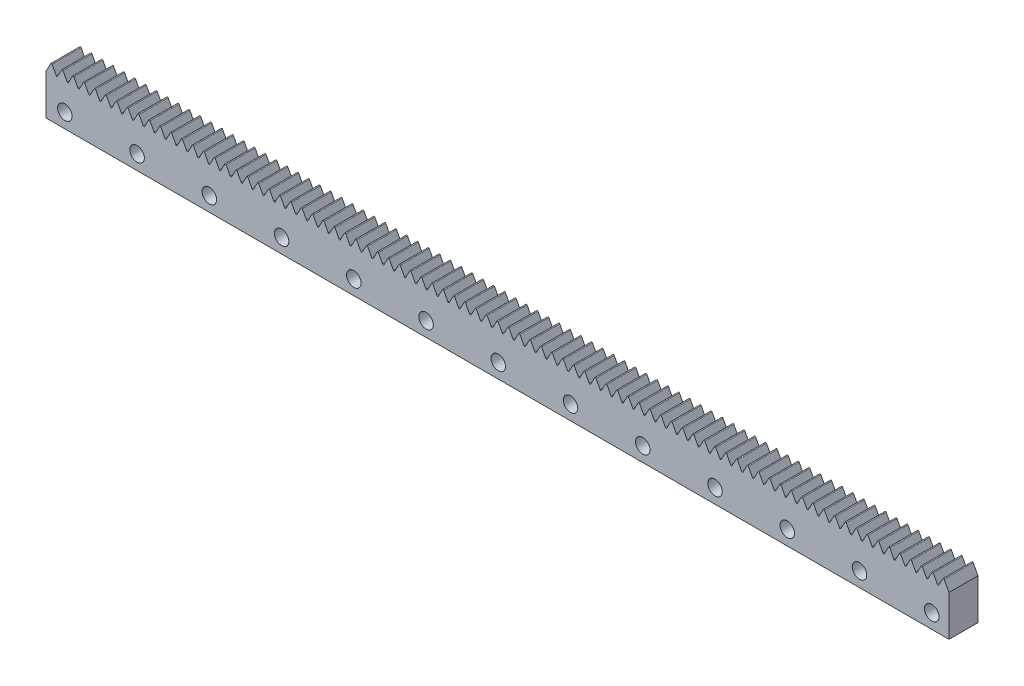
from build123d import *

# Parameters (mm, degrees)
BOSS_EXTRUDE1_DEPTH = 4
SKETCH2_R           = 1
CUT_EXTRUDE1_DEPTH  = 5


with BuildPart() as part:
    # Sketch1 → Boss-Extrude1 (new body)
    with BuildSketch(Plane.XY):
        with BuildLine():
            Line((0, 0), (124.5, 0))
            Line((124.5, 0), (124.5, 5.6))
            Line((124.5, 5.6), (123.838147997, 6.835457072))
            ThreePointArc((123.838147997, 6.835457072), (123.75, 6.888234931), (123.661852003, 6.835457072))
            Line((123.661852003, 6.835457072), (123.088147997, 5.764542928))
            ThreePointArc((123.088147997, 5.764542928), (123, 5.711765069), (122.911852003, 5.764542928))
            Line((122.911852003, 5.764542928), (122.338147997, 6.835457072))
            ThreePointArc((122.338147997, 6.835457072), (122.25, 6.888234931), (122.161852003, 6.835457072))
            Line((122.161852003, 6.835457072), (121.588147997, 5.764542928))
            ThreePointArc((121.588147997, 5.764542928), (121.5, 5.711765069), (121.411852003, 5.764542928))
            Line((121.411852003, 5.764542928), (120.838147997, 6.835457072))
            ThreePointArc((120.838147997, 6.835457072), (120.75, 6.888234931), (120.661852003, 6.835457072))
            Line((120.661852003, 6.835457072), (120.088147997, 5.764542928))
            ThreePointArc((120.088147997, 5.764542928), (120, 5.711765069), (119.911852003, 5.764542928))
            Line((119.911852003, 5.764542928), (119.338147997, 6.835457072))
            ThreePointArc((119.338147997, 6.835457072), (119.25, 6.888234931), (119.161852003, 6.835457072))
            Line((119.161852003, 6.835457072), (118.588147997, 5.764542928))
            ThreePointArc((118.588147997, 5.764542928), (118.5, 5.711765069), (118.411852003, 5.764542928))
            Line((118.411852003, 5.764542928), (117.838147997, 6.835457072))
            ThreePointArc((117.838147997, 6.835457072), (117.75, 6.888234931), (117.661852003, 6.835457072))
            Line((117.661852003, 6.835457072), (117.088147997, 5.764542928))
            ThreePointArc((117.088147997, 5.764542928), (117, 5.711765069), (116.911852003, 5.764542928))
            Line((116.911852003, 5.764542928), (116.338147997, 6.835457072))
            ThreePointArc((116.338147997, 6.835457072), (116.25, 6.888234931), (116.161852003, 6.835457072))
            Line((116.161852003, 6.835457072), (115.588147997, 5.764542928))
            ThreePointArc((115.588147997, 5.764542928), (115.5, 5.711765069), (115.411852003, 5.764542928))
            Line((115.411852003, 5.764542928), (114.838147997, 6.835457072))
            ThreePointArc((114.838147997, 6.835457072), (114.75, 6.888234931), (114.661852003, 6.835457072))
            Line((114.661852003, 6.835457072), (114.088147997, 5.764542928))
            ThreePointArc((114.088147997, 5.764542928), (114, 5.711765069), (113.911852003, 5.764542928))
            Line((113.911852003, 5.764542928), (113.338147997, 6.835457072))
            ThreePointArc((113.338147997, 6.835457072), (113.25, 6.888234931), (113.161852003, 6.835457072))
            Line((113.161852003, 6.835457072), (112.588147997, 5.764542928))
            ThreePointArc((112.588147997, 5.764542928), (112.5, 5.711765069), (112.411852003, 5.764542928))
            Line((112.411852003, 5.764542928), (111.838147997, 6.835457072))
            ThreePointArc((111.838147997, 6.835457072), (111.75, 6.888234931), (111.661852003, 6.835457072))
            Line((111.661852003, 6.835457072), (111.088147997, 5.764542928))
            ThreePointArc((111.088147997, 5.764542928), (111, 5.711765069), (110.911852003, 5.764542928))
            Line((110.911852003, 5.764542928), (110.338147997, 6.835457072))
            ThreePointArc((110.338147997, 6.835457072), (110.25, 6.888234931), (110.161852003, 6.835457072))
            Line((110.161852003, 6.835457072), (109.588147997, 5.764542928))
            ThreePointArc((109.588147997, 5.764542928), (109.5, 5.711765069), (109.411852003, 5.764542928))
            Line((109.411852003, 5.764542928), (108.838147997, 6.835457072))
            ThreePointArc((108.838147997, 6.835457072), (108.75, 6.888234931), (108.661852003, 6.835457072))
            Line((108.661852003, 6.835457072), (108.088147997, 5.764542928))
            ThreePointArc((108.088147997, 5.764542928), (108, 5.711765069), (107.911852003, 5.764542928))
            Line((107.911852003, 5.764542928), (107.338147997, 6.835457072))
            ThreePointArc((107.338147997, 6.835457072), (107.25, 6.888234931), (107.161852003, 6.835457072))
            Line((107.161852003, 6.835457072), (106.588147997, 5.764542928))
            ThreePointArc((106.588147997, 5.764542928), (106.5, 5.711765069), (106.411852003, 5.764542928))
            Line((106.411852003, 5.764542928), (105.838147997, 6.835457072))
            ThreePointArc((105.838147997, 6.835457072), (105.75, 6.888234931), (105.661852003, 6.835457072))
            Line((105.661852003, 6.835457072), (105.088147997, 5.764542928))
            ThreePointArc((105.088147997, 5.764542928), (105, 5.711765069), (104.911852003, 5.764542928))
            Line((104.911852003, 5.764542928), (104.338147997, 6.835457072))
            ThreePointArc((104.338147997, 6.835457072), (104.25, 6.888234931), (104.161852003, 6.835457072))
            Line((104.161852003, 6.835457072), (103.588147997, 5.764542928))
            ThreePointArc((103.588147997, 5.764542928), (103.5, 5.711765069), (103.411852003, 5.764542928))
            Line((103.411852003, 5.764542928), (102.838147997, 6.835457072))
            ThreePointArc((102.838147997, 6.835457072), (102.75, 6.888234931), (102.661852003, 6.835457072))
            Line((102.661852003, 6.835457072), (102.088147997, 5.764542928))
            ThreePointArc((102.088147997, 5.764542928), (102, 5.711765069), (101.911852003, 5.764542928))
            Line((101.911852003, 5.764542928), (101.338147997, 6.835457072))
            ThreePointArc((101.338147997, 6.835457072), (101.25, 6.888234931), (101.161852003, 6.835457072))
            Line((101.161852003, 6.835457072), (100.588147997, 5.764542928))
            ThreePointArc((100.588147997, 5.764542928), (100.5, 5.711765069), (100.411852003, 5.764542928))
            Line((100.411852003, 5.764542928), (99.838147997, 6.835457072))
            ThreePointArc((99.838147997, 6.835457072), (99.75, 6.888234931), (99.661852003, 6.835457072))
            Line((99.661852003, 6.835457072), (99.088147997, 5.764542928))
            ThreePointArc((99.088147997, 5.764542928), (99, 5.711765069), (98.911852003, 5.764542928))
            Line((98.911852003, 5.764542928), (98.338147997, 6.835457072))
            ThreePointArc((98.338147997, 6.835457072), (98.25, 6.888234931), (98.161852003, 6.835457072))
            Line((98.161852003, 6.835457072), (97.588147997, 5.764542928))
            ThreePointArc((97.588147997, 5.764542928), (97.5, 5.711765069), (97.411852003, 5.764542928))
            Line((97.411852003, 5.764542928), (96.838147997, 6.835457072))
            ThreePointArc((96.838147997, 6.835457072), (96.75, 6.888234931), (96.661852003, 6.835457072))
            Line((96.661852003, 6.835457072), (96.088147997, 5.764542928))
            ThreePointArc((96.088147997, 5.764542928), (96, 5.711765069), (95.911852003, 5.764542928))
            Line((95.911852003, 5.764542928), (95.338147997, 6.835457072))
            ThreePointArc((95.338147997, 6.835457072), (95.25, 6.888234931), (95.161852003, 6.835457072))
            Line((95.161852003, 6.835457072), (94.588147997, 5.764542928))
            ThreePointArc((94.588147997, 5.764542928), (94.5, 5.711765069), (94.411852003, 5.764542928))
            Line((94.411852003, 5.764542928), (93.838147997, 6.835457072))
            ThreePointArc((93.838147997, 6.835457072), (93.75, 6.888234931), (93.661852003, 6.835457072))
            Line((93.661852003, 6.835457072), (93.088147997, 5.764542928))
            ThreePointArc((93.088147997, 5.764542928), (93, 5.711765069), (92.911852003, 5.764542928))
            Line((92.911852003, 5.764542928), (92.338147997, 6.835457072))
            ThreePointArc((92.338147997, 6.835457072), (92.25, 6.888234931), (92.161852003, 6.835457072))
            Line((92.161852003, 6.835457072), (91.588147997, 5.764542928))
            ThreePointArc((91.588147997, 5.764542928), (91.5, 5.711765069), (91.411852003, 5.764542928))
            Line((91.411852003, 5.764542928), (90.838147997, 6.835457072))
            ThreePointArc((90.838147997, 6.835457072), (90.75, 6.888234931), (90.661852003, 6.835457072))
            Line((90.661852003, 6.835457072), (90.088147997, 5.764542928))
            ThreePointArc((90.088147997, 5.764542928), (90, 5.711765069), (89.911852003, 5.764542928))
            Line((89.911852003, 5.764542928), (89.338147997, 6.835457072))
            ThreePointArc((89.338147997, 6.835457072), (89.25, 6.888234931), (89.161852003, 6.835457072))
            Line((89.161852003, 6.835457072), (88.588147997, 5.764542928))
            ThreePointArc((88.588147997, 5.764542928), (88.5, 5.711765069), (88.411852003, 5.764542928))
            Line((88.411852003, 5.764542928), (87.838147997, 6.835457072))
            ThreePointArc((87.838147997, 6.835457072), (87.75, 6.888234931), (87.661852003, 6.835457072))
            Line((87.661852003, 6.835457072), (87.088147997, 5.764542928))
            ThreePointArc((87.088147997, 5.764542928), (87, 5.711765069), (86.911852003, 5.764542928))
            Line((86.911852003, 5.764542928), (86.338147997, 6.835457072))
            ThreePointArc((86.338147997, 6.835457072), (86.25, 6.888234931), (86.161852003, 6.835457072))
            Line((86.161852003, 6.835457072), (85.588147997, 5.764542928))
            ThreePointArc((85.588147997, 5.764542928), (85.5, 5.711765069), (85.411852003, 5.764542928))
            Line((85.411852003, 5.764542928), (84.838147997, 6.835457072))
            ThreePointArc((84.838147997, 6.835457072), (84.75, 6.888234931), (84.661852003, 6.835457072))
            Line((84.661852003, 6.835457072), (84.088147997, 5.764542928))
            ThreePointArc((84.088147997, 5.764542928), (84, 5.711765069), (83.911852003, 5.764542928))
            Line((83.911852003, 5.764542928), (83.338147997, 6.835457072))
            ThreePointArc((83.338147997, 6.835457072), (83.25, 6.888234931), (83.161852003, 6.835457072))
            Line((83.161852003, 6.835457072), (82.588147997, 5.764542928))
            ThreePointArc((82.588147997, 5.764542928), (82.5, 5.711765069), (82.411852003, 5.764542928))
            Line((82.411852003, 5.764542928), (81.838147997, 6.835457072))
            ThreePointArc((81.838147997, 6.835457072), (81.75, 6.888234931), (81.661852003, 6.835457072))
            Line((81.661852003, 6.835457072), (81.088147997, 5.764542928))
            ThreePointArc((81.088147997, 5.764542928), (81, 5.711765069), (80.911852003, 5.764542928))
            Line((80.911852003, 5.764542928), (80.338147997, 6.835457072))
            ThreePointArc((80.338147997, 6.835457072), (80.25, 6.888234931), (80.161852003, 6.835457072))
            Line((80.161852003, 6.835457072), (79.588147997, 5.764542928))
            ThreePointArc((79.588147997, 5.764542928), (79.5, 5.711765069), (79.411852003, 5.764542928))
            Line((79.411852003, 5.764542928), (78.838147997, 6.835457072))
            ThreePointArc((78.838147997, 6.835457072), (78.75, 6.888234931), (78.661852003, 6.835457072))
            Line((78.661852003, 6.835457072), (78.088147997, 5.764542928))
            ThreePointArc((78.088147997, 5.764542928), (78, 5.711765069), (77.911852003, 5.764542928))
            Line((77.911852003, 5.764542928), (77.338147997, 6.835457072))
            ThreePointArc((77.338147997, 6.835457072), (77.25, 6.888234931), (77.161852003, 6.835457072))
            Line((77.161852003, 6.835457072), (76.588147997, 5.764542928))
            ThreePointArc((76.588147997, 5.764542928), (76.5, 5.711765069), (76.411852003, 5.764542928))
            Line((76.411852003, 5.764542928), (75.838147997, 6.835457072))
            ThreePointArc((75.838147997, 6.835457072), (75.75, 6.888234931), (75.661852003, 6.835457072))
            Line((75.661852003, 6.835457072), (75.088147997, 5.764542928))
            ThreePointArc((75.088147997, 5.764542928), (75, 5.711765069), (74.911852003, 5.764542928))
            Line((74.911852003, 5.764542928), (74.338147997, 6.835457072))
            ThreePointArc((74.338147997, 6.835457072), (74.25, 6.888234931), (74.161852003, 6.835457072))
            Line((74.161852003, 6.835457072), (73.588147997, 5.764542928))
            ThreePointArc((73.588147997, 5.764542928), (73.5, 5.711765069), (73.411852003, 5.764542928))
            Line((73.411852003, 5.764542928), (72.838147997, 6.835457072))
            ThreePointArc((72.838147997, 6.835457072), (72.75, 6.888234931), (72.661852003, 6.835457072))
            Line((72.661852003, 6.835457072), (72.088147997, 5.764542928))
            ThreePointArc((72.088147997, 5.764542928), (72, 5.711765069), (71.911852003, 5.764542928))
            Line((71.911852003, 5.764542928), (71.338147997, 6.835457072))
            ThreePointArc((71.338147997, 6.835457072), (71.25, 6.888234931), (71.161852003, 6.835457072))
            Line((71.161852003, 6.835457072), (70.588147997, 5.764542928))
            ThreePointArc((70.588147997, 5.764542928), (70.5, 5.711765069), (70.411852003, 5.764542928))
            Line((70.411852003, 5.764542928), (69.838147997, 6.835457072))
            ThreePointArc((69.838147997, 6.835457072), (69.75, 6.888234931), (69.661852003, 6.835457072))
            Line((69.661852003, 6.835457072), (69.088147997, 5.764542928))
            ThreePointArc((69.088147997, 5.764542928), (69, 5.711765069), (68.911852003, 5.764542928))
            Line((68.911852003, 5.764542928), (68.338147997, 6.835457072))
            ThreePointArc((68.338147997, 6.835457072), (68.25, 6.888234931), (68.161852003, 6.835457072))
            Line((68.161852003, 6.835457072), (67.588147997, 5.764542928))
            ThreePointArc((67.588147997, 5.764542928), (67.5, 5.711765069), (67.411852003, 5.764542928))
            Line((67.411852003, 5.764542928), (66.838147997, 6.835457072))
            ThreePointArc((66.838147997, 6.835457072), (66.75, 6.888234931), (66.661852003, 6.835457072))
            Line((66.661852003, 6.835457072), (66.088147997, 5.764542928))
            ThreePointArc((66.088147997, 5.764542928), (66, 5.711765069), (65.911852003, 5.764542928))
            Line((65.911852003, 5.764542928), (65.338147997, 6.835457072))
            ThreePointArc((65.338147997, 6.835457072), (65.25, 6.888234931), (65.161852003, 6.835457072))
            Line((65.161852003, 6.835457072), (64.588147997, 5.764542928))
            ThreePointArc((64.588147997, 5.764542928), (64.5, 5.711765069), (64.411852003, 5.764542928))
            Line((64.411852003, 5.764542928), (63.838147997, 6.835457072))
            ThreePointArc((63.838147997, 6.835457072), (63.75, 6.888234931), (63.661852003, 6.835457072))
            Line((63.661852003, 6.835457072), (63.088147997, 5.764542928))
            ThreePointArc((63.088147997, 5.764542928), (63, 5.711765069), (62.911852003, 5.764542928))
            Line((62.911852003, 5.764542928), (62.338147997, 6.835457072))
            ThreePointArc((62.338147997, 6.835457072), (62.25, 6.888234931), (62.161852003, 6.835457072))
            Line((62.161852003, 6.835457072), (61.588147997, 5.764542928))
            ThreePointArc((61.588147997, 5.764542928), (61.5, 5.711765069), (61.411852003, 5.764542928))
            Line((61.411852003, 5.764542928), (60.838147997, 6.835457072))
            ThreePointArc((60.838147997, 6.835457072), (60.75, 6.888234931), (60.661852003, 6.835457072))
            Line((60.661852003, 6.835457072), (60.088147997, 5.764542928))
            ThreePointArc((60.088147997, 5.764542928), (60, 5.711765069), (59.911852003, 5.764542928))
            Line((59.911852003, 5.764542928), (59.338147997, 6.835457072))
            ThreePointArc((59.338147997, 6.835457072), (59.25, 6.888234931), (59.161852003, 6.835457072))
            Line((59.161852003, 6.835457072), (58.588147997, 5.764542928))
            ThreePointArc((58.588147997, 5.764542928), (58.5, 5.711765069), (58.411852003, 5.764542928))
            Line((58.411852003, 5.764542928), (57.838147997, 6.835457072))
            ThreePointArc((57.838147997, 6.835457072), (57.75, 6.888234931), (57.661852003, 6.835457072))
            Line((57.661852003, 6.835457072), (57.088147997, 5.764542928))
            ThreePointArc((57.088147997, 5.764542928), (57, 5.711765069), (56.911852003, 5.764542928))
            Line((56.911852003, 5.764542928), (56.338147997, 6.835457072))
            ThreePointArc((56.338147997, 6.835457072), (56.25, 6.888234931), (56.161852003, 6.835457072))
            Line((56.161852003, 6.835457072), (55.588147997, 5.764542928))
            ThreePointArc((55.588147997, 5.764542928), (55.5, 5.711765069), (55.411852003, 5.764542928))
            Line((55.411852003, 5.764542928), (54.838147997, 6.835457072))
            ThreePointArc((54.838147997, 6.835457072), (54.75, 6.888234931), (54.661852003, 6.835457072))
            Line((54.661852003, 6.835457072), (54.088147997, 5.764542928))
            ThreePointArc((54.088147997, 5.764542928), (54, 5.711765069), (53.911852003, 5.764542928))
            Line((53.911852003, 5.764542928), (53.338147997, 6.835457072))
            ThreePointArc((53.338147997, 6.835457072), (53.25, 6.888234931), (53.161852003, 6.835457072))
            Line((53.161852003, 6.835457072), (52.588147997, 5.764542928))
            ThreePointArc((52.588147997, 5.764542928), (52.5, 5.711765069), (52.411852003, 5.764542928))
            Line((52.411852003, 5.764542928), (51.838147997, 6.835457072))
            ThreePointArc((51.838147997, 6.835457072), (51.75, 6.888234931), (51.661852003, 6.835457072))
            Line((51.661852003, 6.835457072), (51.088147997, 5.764542928))
            ThreePointArc((51.088147997, 5.764542928), (51, 5.711765069), (50.911852003, 5.764542928))
            Line((50.911852003, 5.764542928), (50.338147997, 6.835457072))
            ThreePointArc((50.338147997, 6.835457072), (50.25, 6.888234931), (50.161852003, 6.835457072))
            Line((50.161852003, 6.835457072), (49.588147997, 5.764542928))
            ThreePointArc((49.588147997, 5.764542928), (49.5, 5.711765069), (49.411852003, 5.764542928))
            Line((49.411852003, 5.764542928), (48.838147997, 6.835457072))
            ThreePointArc((48.838147997, 6.835457072), (48.75, 6.888234931), (48.661852003, 6.835457072))
            Line((48.661852003, 6.835457072), (48.088147997, 5.764542928))
            ThreePointArc((48.088147997, 5.764542928), (48, 5.711765069), (47.911852003, 5.764542928))
            Line((47.911852003, 5.764542928), (47.338147997, 6.835457072))
            ThreePointArc((47.338147997, 6.835457072), (47.25, 6.888234931), (47.161852003, 6.835457072))
            Line((47.161852003, 6.835457072), (46.588147997, 5.764542928))
            ThreePointArc((46.588147997, 5.764542928), (46.5, 5.711765069), (46.411852003, 5.764542928))
            Line((46.411852003, 5.764542928), (45.838147997, 6.835457072))
            ThreePointArc((45.838147997, 6.835457072), (45.75, 6.888234931), (45.661852003, 6.835457072))
            Line((45.661852003, 6.835457072), (45.088147997, 5.764542928))
            ThreePointArc((45.088147997, 5.764542928), (45, 5.711765069), (44.911852003, 5.764542928))
            Line((44.911852003, 5.764542928), (44.338147997, 6.835457072))
            ThreePointArc((44.338147997, 6.835457072), (44.25, 6.888234931), (44.161852003, 6.835457072))
            Line((44.161852003, 6.835457072), (43.588147997, 5.764542928))
            ThreePointArc((43.588147997, 5.764542928), (43.5, 5.711765069), (43.411852003, 5.764542928))
            Line((43.411852003, 5.764542928), (42.838147997, 6.835457072))
            ThreePointArc((42.838147997, 6.835457072), (42.75, 6.888234931), (42.661852003, 6.835457072))
            Line((42.661852003, 6.835457072), (42.088147997, 5.764542928))
            ThreePointArc((42.088147997, 5.764542928), (42, 5.711765069), (41.911852003, 5.764542928))
            Line((41.911852003, 5.764542928), (41.338147997, 6.835457072))
            ThreePointArc((41.338147997, 6.835457072), (41.25, 6.888234931), (41.161852003, 6.835457072))
            Line((41.161852003, 6.835457072), (40.588147997, 5.764542928))
            ThreePointArc((40.588147997, 5.764542928), (40.5, 5.711765069), (40.411852003, 5.764542928))
            Line((40.411852003, 5.764542928), (39.838147997, 6.835457072))
            ThreePointArc((39.838147997, 6.835457072), (39.75, 6.888234931), (39.661852003, 6.835457072))
            Line((39.661852003, 6.835457072), (39.088147997, 5.764542928))
            ThreePointArc((39.088147997, 5.764542928), (39, 5.711765069), (38.911852003, 5.764542928))
            Line((38.911852003, 5.764542928), (38.338147997, 6.835457072))
            ThreePointArc((38.338147997, 6.835457072), (38.25, 6.888234931), (38.161852003, 6.835457072))
            Line((38.161852003, 6.835457072), (37.588147997, 5.764542928))
            ThreePointArc((37.588147997, 5.764542928), (37.5, 5.711765069), (37.411852003, 5.764542928))
            Line((37.411852003, 5.764542928), (36.838147997, 6.835457072))
            ThreePointArc((36.838147997, 6.835457072), (36.75, 6.888234931), (36.661852003, 6.835457072))
            Line((36.661852003, 6.835457072), (36.088147997, 5.764542928))
            ThreePointArc((36.088147997, 5.764542928), (36, 5.711765069), (35.911852003, 5.764542928))
            Line((35.911852003, 5.764542928), (35.338147997, 6.835457072))
            ThreePointArc((35.338147997, 6.835457072), (35.25, 6.888234931), (35.161852003, 6.835457072))
            Line((35.161852003, 6.835457072), (34.588147997, 5.764542928))
            ThreePointArc((34.588147997, 5.764542928), (34.5, 5.711765069), (34.411852003, 5.764542928))
            Line((34.411852003, 5.764542928), (33.838147997, 6.835457072))
            ThreePointArc((33.838147997, 6.835457072), (33.75, 6.888234931), (33.661852003, 6.835457072))
            Line((33.661852003, 6.835457072), (33.088147997, 5.764542928))
            ThreePointArc((33.088147997, 5.764542928), (33, 5.711765069), (32.911852003, 5.764542928))
            Line((32.911852003, 5.764542928), (32.338147997, 6.835457072))
            ThreePointArc((32.338147997, 6.835457072), (32.25, 6.888234931), (32.161852003, 6.835457072))
            Line((32.161852003, 6.835457072), (31.588147997, 5.764542928))
            ThreePointArc((31.588147997, 5.764542928), (31.5, 5.711765069), (31.411852003, 5.764542928))
            Line((31.411852003, 5.764542928), (30.838147997, 6.835457072))
            ThreePointArc((30.838147997, 6.835457072), (30.75, 6.888234931), (30.661852003, 6.835457072))
            Line((30.661852003, 6.835457072), (30.088147997, 5.764542928))
            ThreePointArc((30.088147997, 5.764542928), (30, 5.711765069), (29.911852003, 5.764542928))
            Line((29.911852003, 5.764542928), (29.338147997, 6.835457072))
            ThreePointArc((29.338147997, 6.835457072), (29.25, 6.888234931), (29.161852003, 6.835457072))
            Line((29.161852003, 6.835457072), (28.588147997, 5.764542928))
            ThreePointArc((28.588147997, 5.764542928), (28.5, 5.711765069), (28.411852003, 5.764542928))
            Line((28.411852003, 5.764542928), (27.838147997, 6.835457072))
            ThreePointArc((27.838147997, 6.835457072), (27.75, 6.888234931), (27.661852003, 6.835457072))
            Line((27.661852003, 6.835457072), (27.088147997, 5.764542928))
            ThreePointArc((27.088147997, 5.764542928), (27, 5.711765069), (26.911852003, 5.764542928))
            Line((26.911852003, 5.764542928), (26.338147997, 6.835457072))
            ThreePointArc((26.338147997, 6.835457072), (26.25, 6.888234931), (26.161852003, 6.835457072))
            Line((26.161852003, 6.835457072), (25.588147997, 5.764542928))
            ThreePointArc((25.588147997, 5.764542928), (25.5, 5.711765069), (25.411852003, 5.764542928))
            Line((25.411852003, 5.764542928), (24.838147997, 6.835457072))
            ThreePointArc((24.838147997, 6.835457072), (24.75, 6.888234931), (24.661852003, 6.835457072))
            Line((24.661852003, 6.835457072), (24.088147997, 5.764542928))
            ThreePointArc((24.088147997, 5.764542928), (24, 5.711765069), (23.911852003, 5.764542928))
            Line((23.911852003, 5.764542928), (23.338147997, 6.835457072))
            ThreePointArc((23.338147997, 6.835457072), (23.25, 6.888234931), (23.161852003, 6.835457072))
            Line((23.161852003, 6.835457072), (22.588147997, 5.764542928))
            ThreePointArc((22.588147997, 5.764542928), (22.5, 5.711765069), (22.411852003, 5.764542928))
            Line((22.411852003, 5.764542928), (21.838147997, 6.835457072))
            ThreePointArc((21.838147997, 6.835457072), (21.75, 6.888234931), (21.661852003, 6.835457072))
            Line((21.661852003, 6.835457072), (21.088147997, 5.764542928))
            ThreePointArc((21.088147997, 5.764542928), (21, 5.711765069), (20.911852003, 5.764542928))
            Line((20.911852003, 5.764542928), (20.338147997, 6.835457072))
            ThreePointArc((20.338147997, 6.835457072), (20.25, 6.888234931), (20.161852003, 6.835457072))
            Line((20.161852003, 6.835457072), (19.588147997, 5.764542928))
            ThreePointArc((19.588147997, 5.764542928), (19.5, 5.711765069), (19.411852003, 5.764542928))
            Line((19.411852003, 5.764542928), (18.838147997, 6.835457072))
            ThreePointArc((18.838147997, 6.835457072), (18.75, 6.888234931), (18.661852003, 6.835457072))
            Line((18.661852003, 6.835457072), (18.088147997, 5.764542928))
            ThreePointArc((18.088147997, 5.764542928), (18, 5.711765069), (17.911852003, 5.764542928))
            Line((17.911852003, 5.764542928), (17.338147997, 6.835457072))
            ThreePointArc((17.338147997, 6.835457072), (17.25, 6.888234931), (17.161852003, 6.835457072))
            Line((17.161852003, 6.835457072), (16.588147997, 5.764542928))
            ThreePointArc((16.588147997, 5.764542928), (16.5, 5.711765069), (16.411852003, 5.764542928))
            Line((16.411852003, 5.764542928), (15.838147997, 6.835457072))
            ThreePointArc((15.838147997, 6.835457072), (15.75, 6.888234931), (15.661852003, 6.835457072))
            Line((15.661852003, 6.835457072), (15.088147997, 5.764542928))
            ThreePointArc((15.088147997, 5.764542928), (15, 5.711765069), (14.911852003, 5.764542928))
            Line((14.911852003, 5.764542928), (14.338147997, 6.835457072))
            ThreePointArc((14.338147997, 6.835457072), (14.25, 6.888234931), (14.161852003, 6.835457072))
            Line((14.161852003, 6.835457072), (13.588147997, 5.764542928))
            ThreePointArc((13.588147997, 5.764542928), (13.5, 5.711765069), (13.411852003, 5.764542928))
            Line((13.411852003, 5.764542928), (12.838147997, 6.835457072))
            ThreePointArc((12.838147997, 6.835457072), (12.75, 6.888234931), (12.661852003, 6.835457072))
            Line((12.661852003, 6.835457072), (12.088147997, 5.764542928))
            ThreePointArc((12.088147997, 5.764542928), (12, 5.711765069), (11.911852003, 5.764542928))
            Line((11.911852003, 5.764542928), (11.338147997, 6.835457072))
            ThreePointArc((11.338147997, 6.835457072), (11.25, 6.888234931), (11.161852003, 6.835457072))
            Line((11.161852003, 6.835457072), (10.588147997, 5.764542928))
            ThreePointArc((10.588147997, 5.764542928), (10.5, 5.711765069), (10.411852003, 5.764542928))
            Line((10.411852003, 5.764542928), (9.838147997, 6.835457072))
            ThreePointArc((9.838147997, 6.835457072), (9.75, 6.888234931), (9.661852003, 6.835457072))
            Line((9.661852003, 6.835457072), (9.088147997, 5.764542928))
            ThreePointArc((9.088147997, 5.764542928), (9, 5.711765069), (8.911852003, 5.764542928))
            Line((8.911852003, 5.764542928), (8.338147997, 6.835457072))
            ThreePointArc((8.338147997, 6.835457072), (8.25, 6.888234931), (8.161852003, 6.835457072))
            Line((8.161852003, 6.835457072), (7.588147997, 5.764542928))
            ThreePointArc((7.588147997, 5.764542928), (7.5, 5.711765069), (7.411852003, 5.764542928))
            Line((7.411852003, 5.764542928), (6.838147997, 6.835457072))
            ThreePointArc((6.838147997, 6.835457072), (6.75, 6.888234931), (6.661852003, 6.835457072))
            Line((6.661852003, 6.835457072), (6.088147997, 5.764542928))
            ThreePointArc((6.088147997, 5.764542928), (6, 5.711765069), (5.911852003, 5.764542928))
            Line((5.911852003, 5.764542928), (5.338147997, 6.835457072))
            ThreePointArc((5.338147997, 6.835457072), (5.25, 6.888234931), (5.161852003, 6.835457072))
            Line((5.161852003, 6.835457072), (4.588147997, 5.764542928))
            ThreePointArc((4.588147997, 5.764542928), (4.5, 5.711765069), (4.411852003, 5.764542928))
            Line((4.411852003, 5.764542928), (3.838147997, 6.835457072))
            ThreePointArc((3.838147997, 6.835457072), (3.75, 6.888234931), (3.661852003, 6.835457072))
            Line((3.661852003, 6.835457072), (3.088147997, 5.764542928))
            ThreePointArc((3.088147997, 5.764542928), (3, 5.711765069), (2.911852003, 5.764542928))
            Line((2.911852003, 5.764542928), (2.338147997, 6.835457072))
            ThreePointArc((2.338147997, 6.835457072), (2.25, 6.888234931), (2.161852003, 6.835457072))
            Line((2.161852003, 6.835457072), (1.588147997, 5.764542928))
            ThreePointArc((1.588147997, 5.764542928), (1.5, 5.711765069), (1.411852003, 5.764542928))
            Line((1.411852003, 5.764542928), (0.838147997, 6.835457072))
            ThreePointArc((0.838147997, 6.835457072), (0.75, 6.888234931), (0.661852003, 6.835457072))
            Line((0.661852003, 6.835457072), (0, 5.6))
            Line((0, 5.6), (0, 0))
        make_face()
    extrude(amount=BOSS_EXTRUDE1_DEPTH)

    # Sketch2 → Cut-Extrude1 (cut, through all)
    with BuildSketch(Plane.XY.offset(4)):
        with Locations((2.6, 2)):
            Circle(SKETCH2_R)
        with Locations((12.56, 2)):
            Circle(SKETCH2_R)
        with Locations((22.52, 2)):
            Circle(SKETCH2_R)
        with Locations((32.48, 2)):
            Circle(SKETCH2_R)
        with Locations((42.44, 2)):
            Circle(SKETCH2_R)
        with Locations((52.4, 2)):
            Circle(SKETCH2_R)
        with Locations((62.36, 2)):
            Circle(SKETCH2_R)
        with Locations((72.32, 2)):
            Circle(SKETCH2_R)
        with Locations((82.28, 2)):
            Circle(SKETCH2_R)
        with Locations((92.24, 2)):
            Circle(SKETCH2_R)
        with Locations((102.2, 2)):
            Circle(SKETCH2_R)
        with Locations((112.16, 2)):
            Circle(SKETCH2_R)
        with Locations((122.12, 2)):
            Circle(SKETCH2_R)
    extrude(amount=-CUT_EXTRUDE1_DEPTH, mode=Mode.SUBTRACT)


solid = part.part
